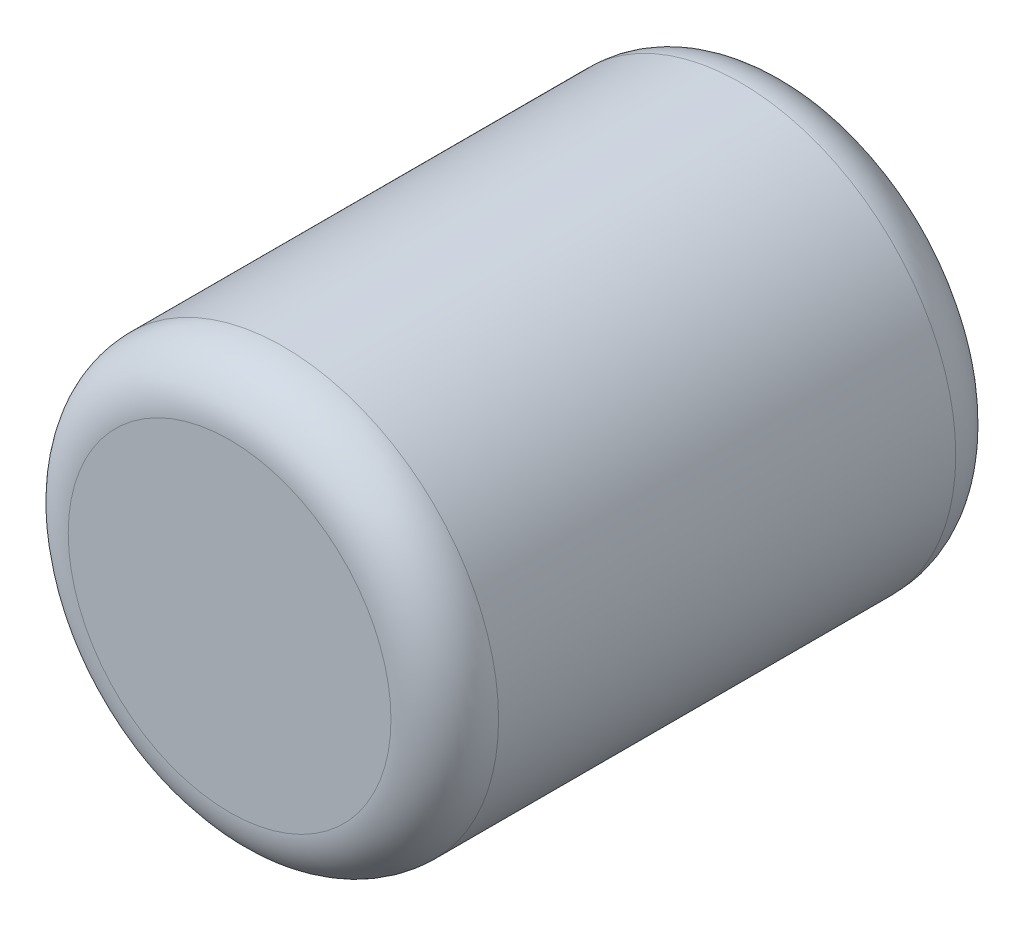
from build123d import *

# Parameters (mm, degrees)
SKETCH1_R           = 50.8
BOSS_EXTRUDE1_DEPTH = 133.35
FILLET1_R           = 12.7


with BuildPart() as part:
    # Sketch1 → Boss-Extrude1 (new body)
    with BuildSketch(Plane.XY):
        Circle(SKETCH1_R)
    extrude(amount=BOSS_EXTRUDE1_DEPTH)

    # Fillet1
    fillet1_edges = [part.edges().sort_by_distance(p)[0] for p in [
        (-50.8, 0, 0),
        (-50.8, 0, 133.35),
    ]]
    fillet(fillet1_edges, radius=FILLET1_R)


solid = part.part
